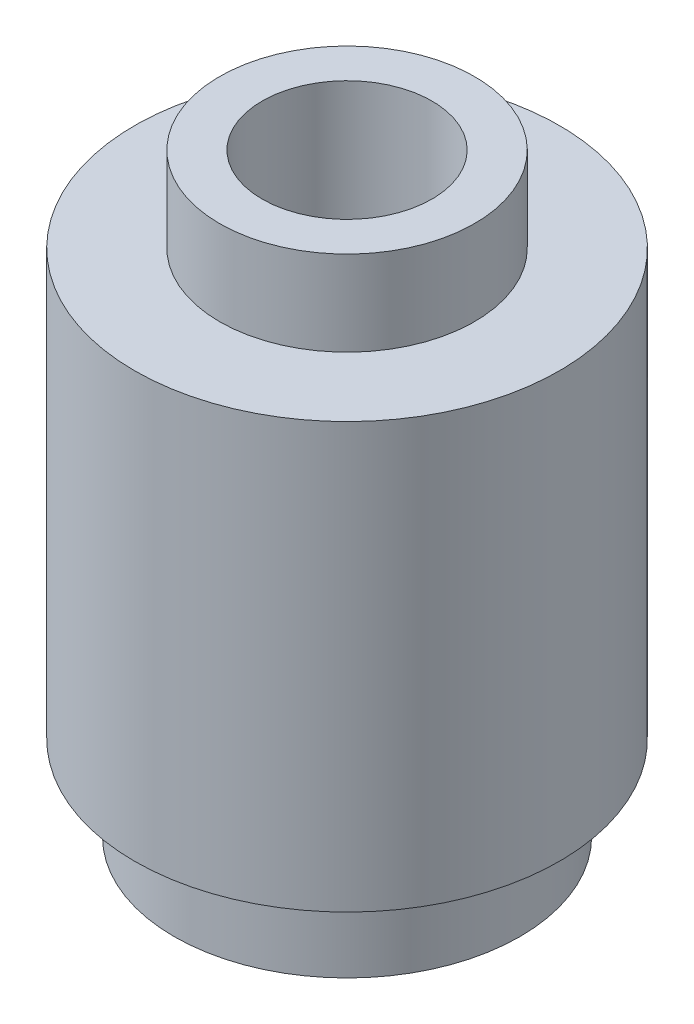
from build123d import *

# Parameters (mm, degrees)
SKETCH1_R                = 2.5
SKETCH1_R_2              = 1.5
BOSS_EXTRUDE1_DEPTH      = 6
SKETCH1_3_R              = 2.5
SKETCH1_3_R_2            = 2.035533906
CUT_EXTRUDE1_DEPTH       = 1
BOSS_EXTRUDE3_DEPTH      = 1
BOSS_EXTRUDE3_DEPTH_BACK = 1
SKETCH2_R                = 1.5
SKETCH2_R_2              = 1


with BuildPart() as part:
    # Sketch1 → Boss-Extrude1 (new body)
    with BuildSketch(Plane(origin=(0, 0, 0), x_dir=(1, 0, 0), z_dir=(0, 1, 0))):
        Circle(SKETCH1_R)
        Circle(SKETCH1_R_2, mode=Mode.SUBTRACT)
    extrude(amount=BOSS_EXTRUDE1_DEPTH)

    # Sketch1_3 → Cut-Extrude1 (cut)
    with BuildSketch(Plane(origin=(0, 0, 0), x_dir=(1, 0, 0), z_dir=(0, 1, 0))):
        Circle(SKETCH1_3_R)
        Circle(SKETCH1_3_R_2, mode=Mode.SUBTRACT)
    extrude(amount=CUT_EXTRUDE1_DEPTH, mode=Mode.SUBTRACT)

    # Sketch2 → Boss-Extrude3 (add, two sides: drawn at the far end of the back side and taken through both)
    with BuildSketch(Plane(origin=(0, 6, 0), x_dir=(1, 0, 0), z_dir=(0, 1, 0)).offset(-BOSS_EXTRUDE3_DEPTH_BACK)):
        Circle(SKETCH2_R)
        Circle(SKETCH2_R_2, mode=Mode.SUBTRACT)
    extrude(amount=BOSS_EXTRUDE3_DEPTH + BOSS_EXTRUDE3_DEPTH_BACK)


solid = part.part
